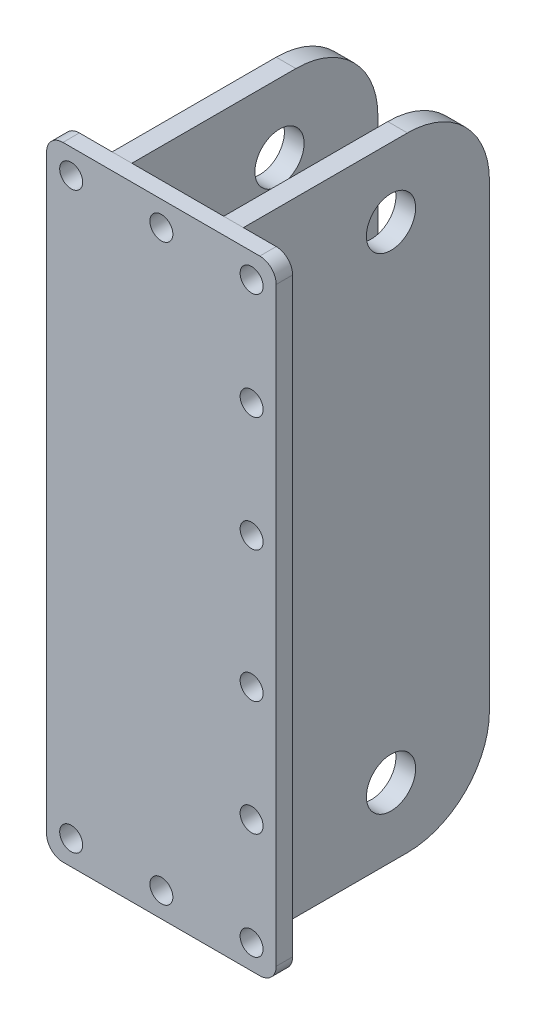
from build123d import *

# Parameters (mm, degrees)
EXTRUDE_1_DEPTH     = 10
CUT_EXTRUDE_1_REACH = 12
SKETCH_2_R          = 7
SKETCH_3_W          = 12
SKETCH_3_H          = 380
EXTRUDE_2_DEPTH     = 150
EXTRUDE_2_2_DEPTH   = 150
FILLET_1_R          = 50
FILLET_2_R          = 50
SKETCH_4_R          = 15
CUT_EXTRUDE_2_DEPTH = 12
SKETCH_5_R          = 15
CUT_EXTRUDE_3_DEPTH = 12


with BuildPart() as part:
    # 草图1 → 凸台-拉伸1 (new body)
    with BuildSketch(Plane.XY):
        with BuildLine():
            Line((10, 0), (130, 0))
            ThreePointArc((130, 0), (137.071067812, 2.928932188), (140, 10))
            Line((140, 10), (140, 370))
            ThreePointArc((140, 370), (137.071067812, 377.071067812), (130, 380))
            Line((130, 380), (10, 380))
            ThreePointArc((10, 380), (2.928932188, 377.071067812), (0, 370))
            Line((0, 370), (0, 10))
            ThreePointArc((0, 10), (2.928932188, 2.928932188), (10, 0))
        make_face()
    extrude(amount=EXTRUDE_1_DEPTH)

    # 草图2 → 切除-拉伸1 (cut, up to next)
    with BuildSketch(Plane.XY.offset(10), mode=Mode.PRIVATE) as cut_extrude_1_sk1:
        with Locations((15, 365)):
            Circle(SKETCH_2_R)
    cut_extrude_1_tool1 = extrude(cut_extrude_1_sk1.sketch, amount=-CUT_EXTRUDE_1_REACH, mode=Mode.PRIVATE) & part.part
    add(cut_extrude_1_tool1.solids().sort_by_distance((15, 365, 10))[0], mode=Mode.SUBTRACT)
    # 草图2 → 切除-拉伸1 (cut, up to next)
    with BuildSketch(Plane.XY.offset(10), mode=Mode.PRIVATE) as cut_extrude_1_sk2:
        with Locations((125, 365)):
            Circle(SKETCH_2_R)
    cut_extrude_1_tool2 = extrude(cut_extrude_1_sk2.sketch, amount=-CUT_EXTRUDE_1_REACH, mode=Mode.PRIVATE) & part.part
    add(cut_extrude_1_tool2.solids().sort_by_distance((125, 365, 10))[0], mode=Mode.SUBTRACT)
    # 草图2 → 切除-拉伸1 (cut, up to next)
    with BuildSketch(Plane.XY.offset(10), mode=Mode.PRIVATE) as cut_extrude_1_sk3:
        with Locations((15, 15)):
            Circle(SKETCH_2_R)
    cut_extrude_1_tool3 = extrude(cut_extrude_1_sk3.sketch, amount=-CUT_EXTRUDE_1_REACH, mode=Mode.PRIVATE) & part.part
    add(cut_extrude_1_tool3.solids().sort_by_distance((15, 15, 10))[0], mode=Mode.SUBTRACT)
    # 草图2 → 切除-拉伸1 (cut, up to next)
    with BuildSketch(Plane.XY.offset(10), mode=Mode.PRIVATE) as cut_extrude_1_sk4:
        with Locations((125, 15)):
            Circle(SKETCH_2_R)
    cut_extrude_1_tool4 = extrude(cut_extrude_1_sk4.sketch, amount=-CUT_EXTRUDE_1_REACH, mode=Mode.PRIVATE) & part.part
    add(cut_extrude_1_tool4.solids().sort_by_distance((125, 15, 10))[0], mode=Mode.SUBTRACT)
    # 草图2 → 切除-拉伸1 (cut, up to next)
    with BuildSketch(Plane.XY.offset(10), mode=Mode.PRIVATE) as cut_extrude_1_sk5:
        with Locations((70, 365)):
            Circle(SKETCH_2_R)
    cut_extrude_1_tool5 = extrude(cut_extrude_1_sk5.sketch, amount=-CUT_EXTRUDE_1_REACH, mode=Mode.PRIVATE) & part.part
    add(cut_extrude_1_tool5.solids().sort_by_distance((70, 365, 10))[0], mode=Mode.SUBTRACT)
    # 草图2 → 切除-拉伸1 (cut, up to next)
    with BuildSketch(Plane.XY.offset(10), mode=Mode.PRIVATE) as cut_extrude_1_sk6:
        with Locations((70, 15)):
            Circle(SKETCH_2_R)
    cut_extrude_1_tool6 = extrude(cut_extrude_1_sk6.sketch, amount=-CUT_EXTRUDE_1_REACH, mode=Mode.PRIVATE) & part.part
    add(cut_extrude_1_tool6.solids().sort_by_distance((70, 15, 10))[0], mode=Mode.SUBTRACT)
    # 草图2 → 切除-拉伸1 (cut, up to next)
    with BuildSketch(Plane.XY.offset(10), mode=Mode.PRIVATE) as cut_extrude_1_sk7:
        with Locations((125, 300)):
            Circle(SKETCH_2_R)
    cut_extrude_1_tool7 = extrude(cut_extrude_1_sk7.sketch, amount=-CUT_EXTRUDE_1_REACH, mode=Mode.PRIVATE) & part.part
    add(cut_extrude_1_tool7.solids().sort_by_distance((125, 300, 10))[0], mode=Mode.SUBTRACT)
    # 草图2 → 切除-拉伸1 (cut, up to next)
    with BuildSketch(Plane.XY.offset(10), mode=Mode.PRIVATE) as cut_extrude_1_sk8:
        with Locations((125, 80)):
            Circle(SKETCH_2_R)
    cut_extrude_1_tool8 = extrude(cut_extrude_1_sk8.sketch, amount=-CUT_EXTRUDE_1_REACH, mode=Mode.PRIVATE) & part.part
    add(cut_extrude_1_tool8.solids().sort_by_distance((125, 80, 10))[0], mode=Mode.SUBTRACT)
    # 草图2 → 切除-拉伸1 (cut, up to next)
    with BuildSketch(Plane.XY.offset(10), mode=Mode.PRIVATE) as cut_extrude_1_sk9:
        with Locations((125, 230)):
            Circle(SKETCH_2_R)
    cut_extrude_1_tool9 = extrude(cut_extrude_1_sk9.sketch, amount=-CUT_EXTRUDE_1_REACH, mode=Mode.PRIVATE) & part.part
    add(cut_extrude_1_tool9.solids().sort_by_distance((125, 230, 10))[0], mode=Mode.SUBTRACT)
    # 草图2 → 切除-拉伸1 (cut, up to next)
    with BuildSketch(Plane.XY.offset(10), mode=Mode.PRIVATE) as cut_extrude_1_sk10:
        with Locations((125, 150)):
            Circle(SKETCH_2_R)
    cut_extrude_1_tool10 = extrude(cut_extrude_1_sk10.sketch, amount=-CUT_EXTRUDE_1_REACH, mode=Mode.PRIVATE) & part.part
    add(cut_extrude_1_tool10.solids().sort_by_distance((125, 150, 10))[0], mode=Mode.SUBTRACT)


with BuildPart() as body_2:
    # 草图3 → 凸台-拉伸2 (new body)
    with BuildSketch(Plane(origin=(0, 0, 0), x_dir=(-1, 0, 0), z_dir=(0, 0, -1))):
        with Locations((-104, 190)):
            Rectangle(SKETCH_3_W, SKETCH_3_H)
    extrude(amount=EXTRUDE_2_DEPTH)

    # 圆角1
    fillet_1_edges = [body_2.edges().sort_by_distance(p)[0] for p in [
        (104, 380, -150),
        (104, 0, -150),
    ]]
    fillet(fillet_1_edges, radius=FILLET_1_R)

    # 草图4 → 切除-拉伸2 (cut)
    with BuildSketch(Plane(origin=(110, 0, 0), x_dir=(0, 0, -1), z_dir=(1, 0, 0))):
        with Locations((90, 338)):
            Circle(SKETCH_4_R)
        with Locations((90, 42)):
            Circle(SKETCH_4_R)
    extrude(amount=-CUT_EXTRUDE_2_DEPTH, mode=Mode.SUBTRACT)


with BuildPart() as body_3:
    # 草图3 → Extrude 2 2 (new body)
    with BuildSketch(Plane(origin=(0, 0, 0), x_dir=(-1, 0, 0), z_dir=(0, 0, -1))):
        with Locations((-36, 190)):
            Rectangle(SKETCH_3_W, SKETCH_3_H)
    extrude(amount=EXTRUDE_2_2_DEPTH)

    # 圆角2
    fillet_2_edges = [body_3.edges().sort_by_distance(p)[0] for p in [
        (36, 380, -150),
        (36, 0, -150),
    ]]
    fillet(fillet_2_edges, radius=FILLET_2_R)

    # 草图5 → 切除-拉伸3 (cut)
    with BuildSketch(Plane.ZY.offset(-30)):
        with Locations((-90, 338)):
            Circle(SKETCH_5_R)
        with Locations((-90, 42)):
            Circle(SKETCH_5_R)
    extrude(amount=-CUT_EXTRUDE_3_DEPTH, mode=Mode.SUBTRACT)


solid = Compound([part.part, body_2.part, body_3.part])
